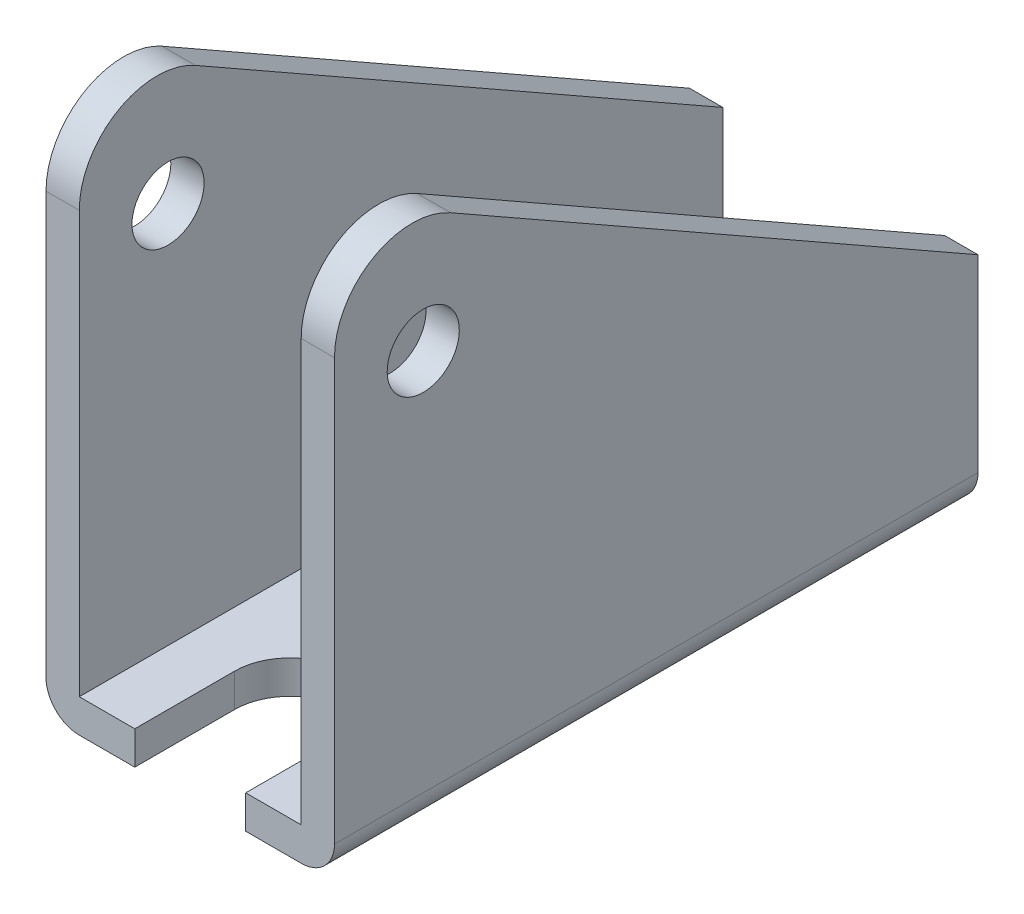
from build123d import *

# Parameters (mm, degrees)
EXTRUDE_1_DEPTH     = 58
SKETCH_2_R          = 3.25
CUT_EXTRUDE_1_DEPTH = 27
FILLET_1_R          = 7
SKETCH_3_R          = 4.5
CUT_EXTRUDE_2_DEPTH = 4
FILLET_2_R          = 3


with BuildPart() as part:
    # 草图1 → 凸台-拉伸1 (new body)
    with BuildSketch(Plane.XY):
        Polygon((-10, -20.797836643), (-10, -72.797836643), (10, -72.797836643), (10, -20.797836643), (13, -20.797836643), (13, -75.797836643), (-13, -75.797836643), (-13, -20.797836643), align=None)
    extrude(amount=EXTRUDE_1_DEPTH)

    # 草图2 → 切除-拉伸1 (cut, through all)
    with BuildSketch(Plane(origin=(13, 0, 0), x_dir=(0, 0, -1), z_dir=(1, 0, 0))):
        with Locations((-50, -38.297836643)):
            Circle(SKETCH_2_R)
        Polygon((-58, -20.797836643), (-58, -22.797836643), (0, -55.797836643), (0, -20.797836643), align=None)
    extrude(amount=-CUT_EXTRUDE_1_DEPTH, mode=Mode.SUBTRACT)

    # 圆角1
    fillet_1_edges = [part.edges().sort_by_distance(p)[0] for p in [
        (11.5, -22.797836643, 58),
        (-11.5, -22.797836643, 58),
    ]]
    fillet(fillet_1_edges, radius=FILLET_1_R)

    # 草图3 → 切除-拉伸2 (cut, through all)
    with BuildSketch(Plane(origin=(0, -72.797836643, 0), x_dir=(1, 0, 0), z_dir=(0, 1, 0))):
        with Locations((0, -12)):
            Circle(SKETCH_3_R)
        with BuildLine():
            Line((5, -49), (5, -58))
            Line((5, -58), (-5, -58))
            Line((-5, -58), (-5, -49))
            ThreePointArc((-5, -49), (0, -44), (5, -49))
        make_face()
    extrude(amount=-CUT_EXTRUDE_2_DEPTH, mode=Mode.SUBTRACT)

    # 圆角2
    fillet_2_edges = [part.edges().sort_by_distance(p)[0] for p in [
        (13, -75.797836643, 29),
        (-13, -75.797836643, 29),
    ]]
    fillet(fillet_2_edges, radius=FILLET_2_R)


solid = part.part
